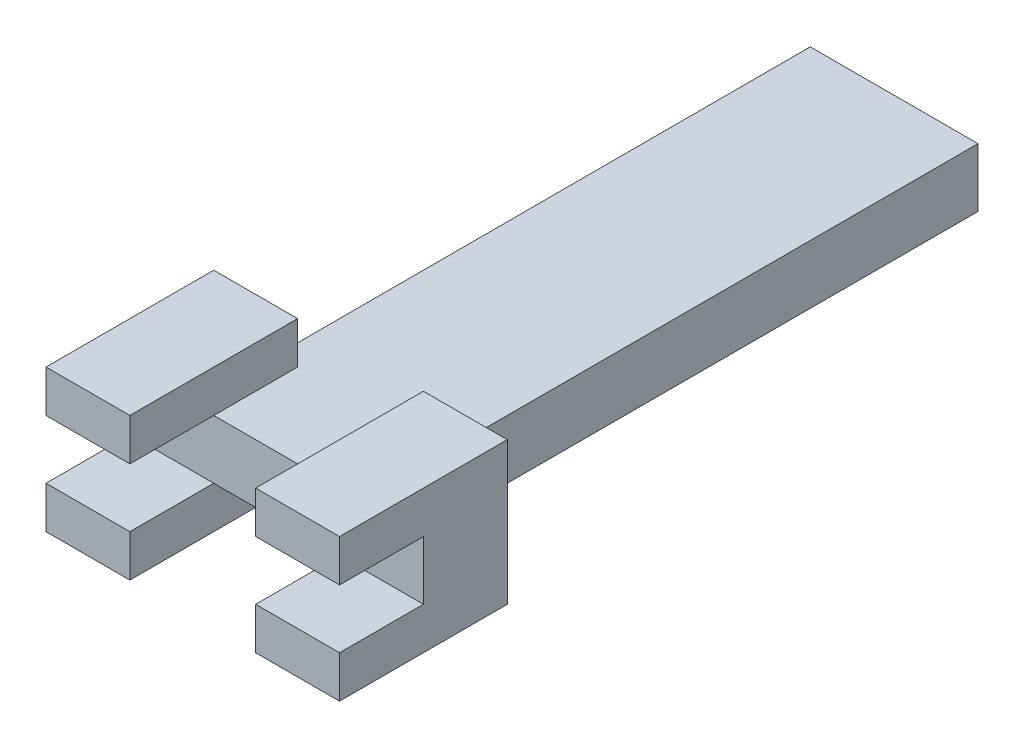
from build123d import *

# Parameters (mm, degrees)
SKETCH1_W           = 20
SKETCH1_H           = 73.625466435
BOSS_EXTRUDE1_DEPTH = 7
SKETCH2_W           = 10
SKETCH2_H           = 10
BOSS_EXTRUDE2_DEPTH = 5
SKETCH3_W           = 10
SKETCH3_H           = 5
BOSS_EXTRUDE3_DEPTH = 10
SKETCH4_W           = 7.5
SKETCH4_H           = 10
BOSS_EXTRUDE4_DEPTH = 3.5


with BuildPart() as part:
    # Sketch1 → Boss-Extrude1 (new body)
    with BuildSketch(Plane(origin=(0, 0, 0), x_dir=(1, 0, 0), z_dir=(0, 1, 0))):
        with Locations((10, 36.812733218)):
            Rectangle(SKETCH1_W, SKETCH1_H)
    extrude(amount=BOSS_EXTRUDE1_DEPTH)

    # Sketch2 → Boss-Extrude2 (add)
    with BuildSketch(Plane(origin=(0, 7, 0), x_dir=(1, 0, 0), z_dir=(0, 1, 0))):
        with Locations((-2.5, 5)):
            Rectangle(SKETCH2_W, SKETCH2_H)
        with Locations((22.5, 5)):
            Rectangle(SKETCH2_W, SKETCH2_H)
    boss_extrude2 = extrude(amount=BOSS_EXTRUDE2_DEPTH)

    # Sketch3 → Boss-Extrude3 (add)
    with BuildSketch(Plane.XY):
        with Locations((-2.5, 9.5)):
            Rectangle(SKETCH3_W, SKETCH3_H)
        with Locations((22.5, 9.5)):
            Rectangle(SKETCH3_W, SKETCH3_H)
    boss_extrude3 = extrude(amount=BOSS_EXTRUDE3_DEPTH)

    # Sketch4 → Boss-Extrude4 (add)
    with BuildSketch(Plane.XZ.offset(-7)):
        with Locations((-3.75, -5)):
            Rectangle(SKETCH4_W, SKETCH4_H)
        with Locations((23.75, -5)):
            Rectangle(SKETCH4_W, SKETCH4_H)
    boss_extrude4 = extrude(amount=BOSS_EXTRUDE4_DEPTH)

    # Mirror1: Boss-Extrude2, Boss-Extrude3, Boss-Extrude4 across plane
    add(boss_extrude2.mirror(Plane.ZX.offset(3.5)))
    add(boss_extrude3.mirror(Plane.ZX.offset(3.5)))
    add(boss_extrude4.mirror(Plane.ZX.offset(3.5)))


solid = part.part
